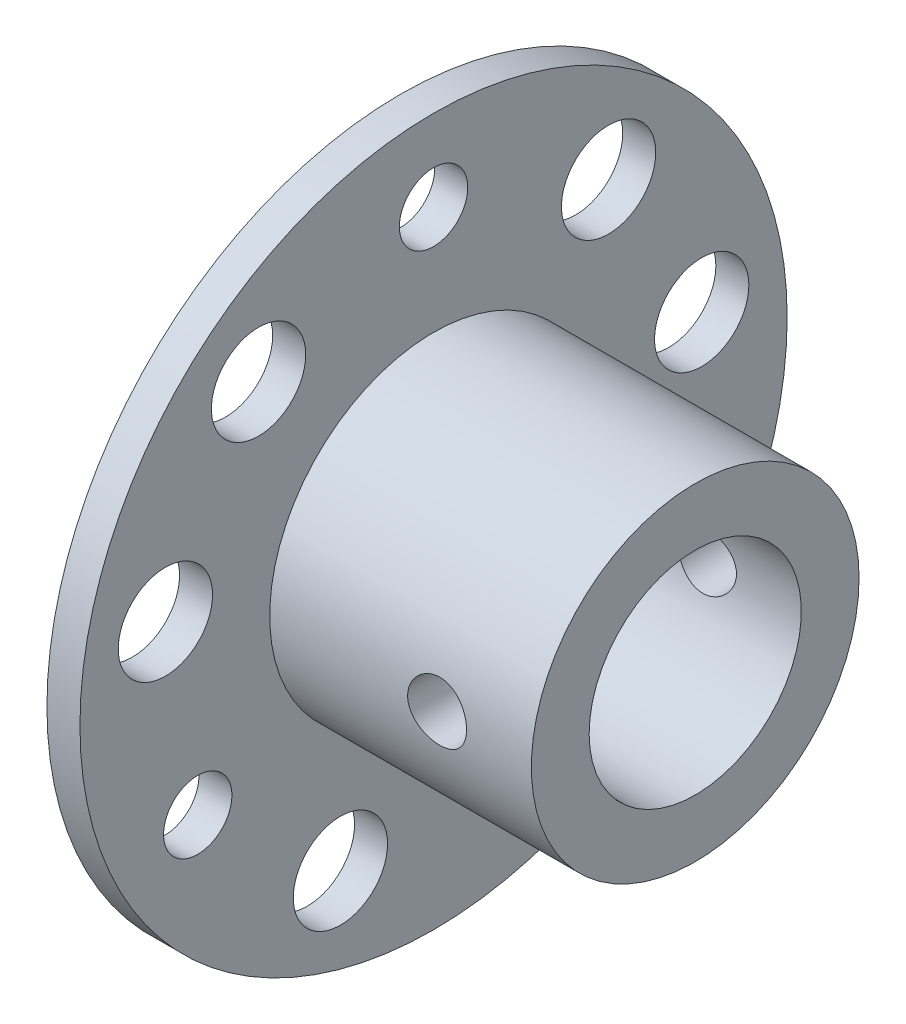
from build123d import *

# Parameters (mm, degrees)
SKETCH1_W                      = 1.4
SKETCH1_H                      = 15
SKETCH2_R                      = 6.95
BOSS_EXTRUDE1_DEPTH            = 11.1
F_4_0_4_DIAMETER_HOLE1_D       = 4
F_4_0_4_DIAMETER_HOLE1_DEPTH   = 1.4
F_2_9_2_9_DIAMETER_HOLE1_D     = 2.9
F_2_9_2_9_DIAMETER_HOLE1_DEPTH = 1.4
F_9_0_9_DIAMETER_HOLE1_D       = 9
F_9_0_9_DIAMETER_HOLE1_DEPTH   = 12.5
SKETCH9_W                      = 1.25
SKETCH9_H                      = 10.677095884
F_2_5_2_5_DIAMETER_HOLE2_D     = 2.5
F_2_5_2_5_DIAMETER_HOLE2_DEPTH = 10.677095884


with BuildPart() as part:
    # Sketch1 → Revolve1 (revolve)
    with BuildSketch(Plane.XY):
        with Locations((0.7, 7.5)):
            Rectangle(SKETCH1_W, SKETCH1_H)
    revolve(axis=Axis((0, 0, 0), (1, 0, 0)))

    # Sketch2 → Boss-Extrude1 (add)
    with BuildSketch(Plane(origin=(1.4, 0, 0), x_dir=(0, 0, -1), z_dir=(1, 0, 0))):
        Circle(SKETCH2_R)
    extrude(amount=BOSS_EXTRUDE1_DEPTH)

    # Ø4.0 (4) Diameter Hole1
    with Locations(Plane(origin=(1.4, 0, 0), x_dir=(0, 0, -1), z_dir=(1, 0, 0))):
        with Locations((-7.424196892, 8.847813318), (-11.374529547, 2.005636452), (-3.950332655, -10.85344977), (3.950332655, -10.85344977), (11.374529547, 2.005636452), (7.424196892, 8.847813318)):
            Hole(F_4_0_4_DIAMETER_HOLE1_D / 2, depth=F_4_0_4_DIAMETER_HOLE1_DEPTH)

    # Ø2.9 (2.9) Diameter Hole1
    with Locations(Plane(origin=(1.4, 0, 0), x_dir=(0, 0, -1), z_dir=(1, 0, 0))):
        with Locations((0, 11.55), (-10.002593414, -5.775), (10.002593414, -5.775)):
            Hole(F_2_9_2_9_DIAMETER_HOLE1_D / 2, depth=F_2_9_2_9_DIAMETER_HOLE1_DEPTH)

    # Ø9.0 (9) Diameter Hole1
    with Locations(Plane.ZY):
        with Locations((0, 0)):
            Hole(F_9_0_9_DIAMETER_HOLE1_D / 2, depth=F_9_0_9_DIAMETER_HOLE1_DEPTH)

    # Sketch9 → Ø2.5 (2.5) Diameter Hole1 (revolve, cut)
    with BuildSketch(Plane(origin=(8.5, 0, -4.322904116), x_dir=(0, -1, 0), z_dir=(1, 0, 0))):
        with Locations((0.625, 5.338547942)):
            Rectangle(SKETCH9_W, SKETCH9_H)
    revolve(axis=Axis((8.5, 0, 2.027095884), (0, 0, -1)), mode=Mode.SUBTRACT)

    # Ø2.5 (2.5) Diameter Hole2
    with Locations(Plane(origin=(0, 0, 4.322904116), x_dir=(-1, 0, 0), z_dir=(0, 0, -1))):
        with Locations((-8.5, 0)):
            Hole(F_2_5_2_5_DIAMETER_HOLE2_D / 2, depth=F_2_5_2_5_DIAMETER_HOLE2_DEPTH)


solid = part.part
